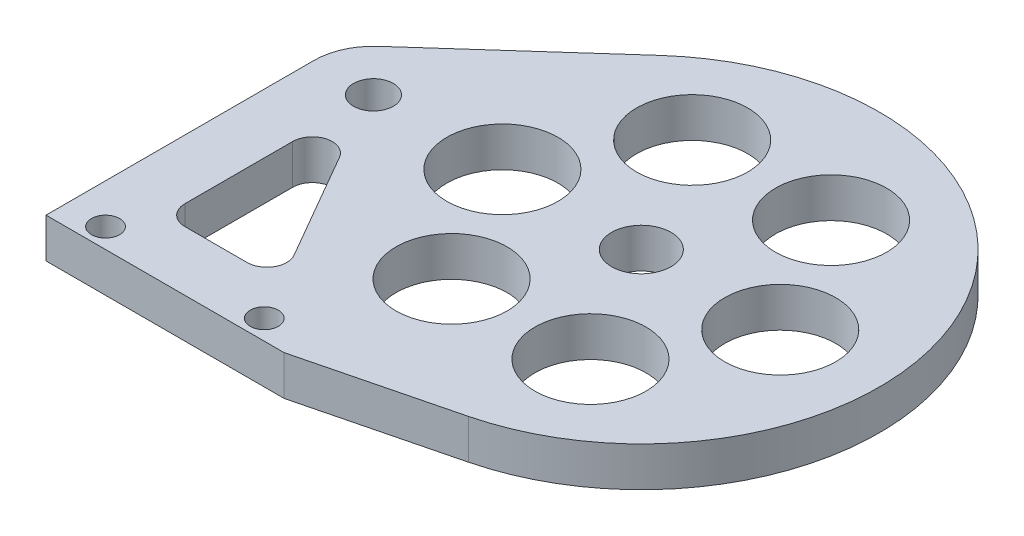
from build123d import *

# Parameters (mm, degrees)
BOSS_EXTRUDE1_DEPTH             = 6.35
F_1_4_0_25_DIAMETER_HOLE1_D     = 6.35
F_1_4_0_25_DIAMETER_HOLE1_DEPTH = 16.51
F_1_4_0_25_DIAMETER_HOLE1_TIP   = 1.907732465
F_8_CLEARANCE_HOLE1_D           = 4.4958
F_8_CLEARANCE_HOLE1_DEPTH       = 16.51
F_8_CLEARANCE_HOLE1_TIP         = 1.350674586
SKETCH7_R                       = 4.7625
CUT_EXTRUDE1_DEPTH              = 7.35
CUT_EXTRUDE2_DEPTH              = 7.35
SKETCH9_R                       = 8.89
CUT_EXTRUDE3_DEPTH              = 7.35


with BuildPart() as part:
    # Sketch1 → Boss-Extrude1 (new body)
    with BuildSketch(Plane(origin=(0, 0, 0), x_dir=(1, 0, 0), z_dir=(0, 1, 0))):
        with BuildLine():
            Line((-52.3875, -42.8625), (-52.3875, 0))
            ThreePointArc((-52.3875, 0), (-51.5575956, 3.888564967), (-49.2125, 7.099515829))
            Line((-49.2125, 7.099515829), (-25.4, 28.398063314))
            ThreePointArc((-25.4, 28.398063314), (15.554259867, 34.780382402), (38.1, 0))
            Line((38.1, 0), (38.1, -42.8625))
            Line((38.1, -42.8625), (-52.3875, -42.8625))
        make_face()
    extrude(amount=BOSS_EXTRUDE1_DEPTH)

    # 1/4 (0.25) Diameter Hole1
    with Locations(Plane(origin=(0, 6.35, 0), x_dir=(1, 0, 0), z_dir=(0, 1, 0))):
        with Locations((-42.8625, 0)):
            Hole(F_1_4_0_25_DIAMETER_HOLE1_D / 2, depth=F_1_4_0_25_DIAMETER_HOLE1_DEPTH)
            with Locations((0, 0, -(F_1_4_0_25_DIAMETER_HOLE1_DEPTH + F_1_4_0_25_DIAMETER_HOLE1_TIP / 2))):  # 118° drill point
                Cone(0, F_1_4_0_25_DIAMETER_HOLE1_D / 2, F_1_4_0_25_DIAMETER_HOLE1_TIP, mode=Mode.SUBTRACT)

    # #8 Clearance Hole1
    with Locations(Plane(origin=(0, 6.35, 0), x_dir=(1, 0, 0), z_dir=(0, 1, 0))):
        with Locations((-46.0375, -39.6875), (-20.6375, -39.6875)):
            Hole(F_8_CLEARANCE_HOLE1_D / 2, depth=F_8_CLEARANCE_HOLE1_DEPTH)
            with Locations((0, 0, -(F_8_CLEARANCE_HOLE1_DEPTH + F_8_CLEARANCE_HOLE1_TIP / 2))):  # 118° drill point
                Cone(0, F_8_CLEARANCE_HOLE1_D / 2, F_8_CLEARANCE_HOLE1_TIP, mode=Mode.SUBTRACT)

    # Sketch7 → Cut-Extrude1 (cut, through all)
    with BuildSketch(Plane(origin=(0, 6.35, 0), x_dir=(1, 0, 0), z_dir=(0, 1, 0))):
        Circle(SKETCH7_R)
    extrude(amount=-CUT_EXTRUDE1_DEPTH, mode=Mode.SUBTRACT)

    # Sketch8 → Cut-Extrude2 (cut, through all)
    with BuildSketch(Plane(origin=(0, 6.35, 0), x_dir=(1, 0, 0), z_dir=(0, 1, 0))):
        with BuildLine():
            Line((-14.2875, -42.8625), (9.267264347, -36.955754782))
            ThreePointArc((9.267264347, -36.955754782), (30.039080975, -23.436373742), (38.1, 0))
            Line((38.1, 0), (38.1, -42.8625))
            Line((38.1, -42.8625), (-14.2875, -42.8625))
        make_face()
    extrude(amount=-CUT_EXTRUDE2_DEPTH, mode=Mode.SUBTRACT)

    # Sketch9 → Cut-Extrude3 (cut, through all)
    with BuildSketch(Plane(origin=(0, 6.35, 0), x_dir=(1, 0, 0), z_dir=(0, 1, 0))):
        with Locations((-22.225, 0)):
            Circle(SKETCH9_R)
        with Locations((-11.1125, 19.247414599)):
            Circle(SKETCH9_R)
        with Locations((11.1125, 19.247414599)):
            Circle(SKETCH9_R)
        with Locations((22.225, 0)):
            Circle(SKETCH9_R)
        with Locations((11.1125, -19.247414599)):
            Circle(SKETCH9_R)
        with Locations((-11.1125, -19.247414599)):
            Circle(SKETCH9_R)
        with BuildLine():
            Line((-42.8625, -12.934062773), (-42.8625, -30.1625))
            ThreePointArc((-42.8625, -30.1625), (-41.93256403, -32.40756403), (-39.6875, -33.3375))
            Line((-39.6875, -33.3375), (-29.740657129, -33.3375))
            ThreePointArc((-29.740657129, -33.3375), (-26.991026472, -31.75), (-26.991026472, -28.575))
            Line((-26.991026472, -28.575), (-36.937869343, -11.346562773))
            ThreePointArc((-36.937869343, -11.346562773), (-40.509250468, -9.867248274), (-42.8625, -12.934062773))
        make_face()
    extrude(amount=-CUT_EXTRUDE3_DEPTH, mode=Mode.SUBTRACT)


solid = part.part
